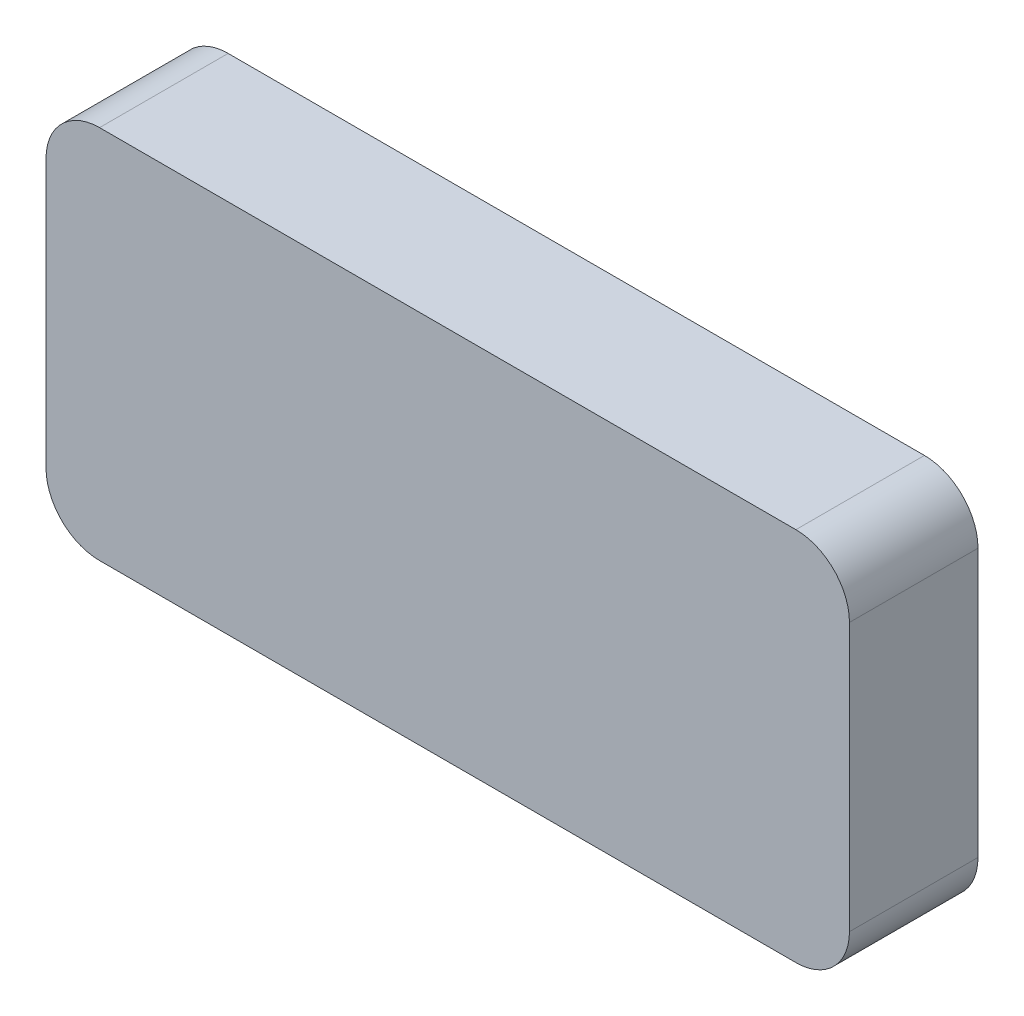
from build123d import *

# Parameters (mm, degrees)
SKETCH1_W           = 75
SKETCH1_H           = 35
BOSS_EXTRUDE1_DEPTH = 12
FILLET1_R           = 5


with BuildPart() as part:
    # Sketch1 → Boss-Extrude1 (new body)
    with BuildSketch(Plane.XY):
        with Locations((37.5, 17.5)):
            Rectangle(SKETCH1_W, SKETCH1_H)
    extrude(amount=BOSS_EXTRUDE1_DEPTH)

    # Fillet1
    fillet1_edges = [part.edges().sort_by_distance(p)[0] for p in [
        (0, 35, 6),
        (75, 35, 6),
        (75, 0, 6),
        (0, 0, 6),
    ]]
    fillet(fillet1_edges, radius=FILLET1_R)


solid = part.part
